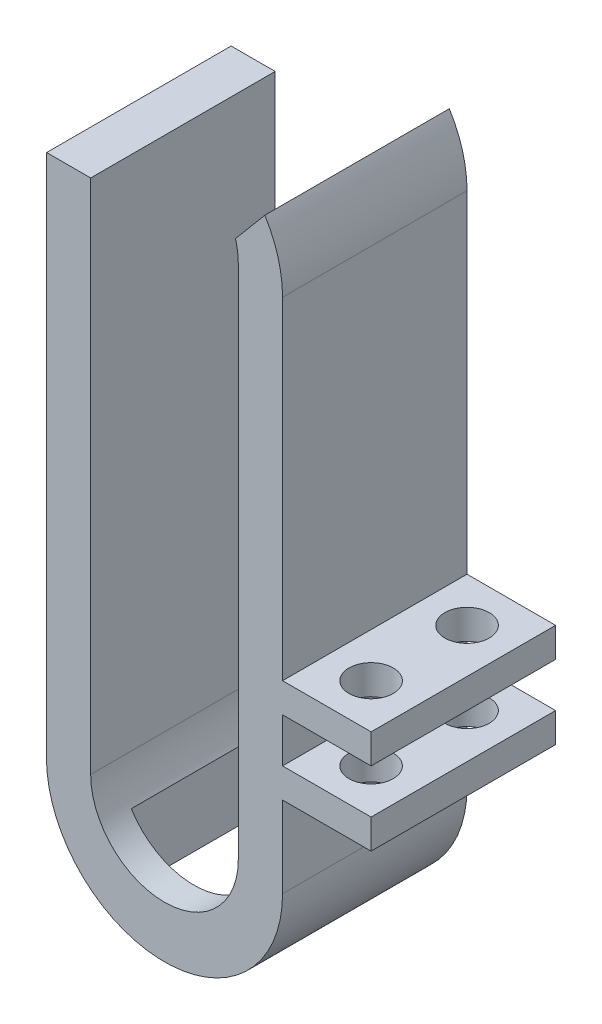
from build123d import *

# Parameters (mm, degrees)
BOSS_EXTRUDE1_DEPTH     = 12.5
SKETCH2_W               = 12.5
SKETCH2_H               = 2
BOSS_EXTRUDE2_DEPTH     = 6
SKETCH3_R               = 1.5
CUT_EXTRUDE1_DEPTH      = 32.713927878
CUT_EXTRUDE1_DEPTH_BACK = 16.499999831
SKETCH5_W               = 8.5
SKETCH5_H               = 8.5
CUT_EXTRUDE2_DEPTH      = 26.999999831


with BuildPart() as part:
    # Sketch1 → Boss-Extrude1 (new body)
    with BuildSketch(Plane.XY):
        with BuildLine():
            ThreePointArc((8, 17), (7.694207367, 19.190701486), (6.80020675, 21.213927878))
            Line((6.80020675, 21.213927878), (4.814885895, 18.847914617))
            ThreePointArc((4.814885895, 18.847914617), (4.953505298, 18.180283222), (5, 17.5))
            Line((5, 17.5), (5, -17.5))
            ThreePointArc((5, -17.5), (0, -22.5), (-5, -17.5))
            Line((-5, -17.5), (-5, 17.5))
            Line((-5, 17.5), (-7.984359711, 17.5))
            ThreePointArc((-7.984359711, 17.5), (-7.996088972, 17.250122279), (-8, 17))
            Line((-8, 17), (-8, -17.999999662))
            ThreePointArc((-8, -17.999999662), (-1.69e-07, -25.999999831), (8, -18))
            Line((8, -18), (8, 17))
        make_face()
    extrude(amount=BOSS_EXTRUDE1_DEPTH)

    # Sketch2 → Boss-Extrude2 (add)
    with BuildSketch(Plane(origin=(8, 0, 0), x_dir=(0, 0, -1), z_dir=(1, 0, 0))):
        with Locations((-6.25, -11.5)):
            Rectangle(SKETCH2_W, SKETCH2_H)
        with Locations((-6.25, -6.5)):
            Rectangle(SKETCH2_W, SKETCH2_H)
    extrude(amount=BOSS_EXTRUDE2_DEPTH)

    # Sketch3 → Cut-Extrude1 (cut, two sides)
    with BuildSketch(Plane(origin=(0, -10.5, 0), x_dir=(1, 0, 0), z_dir=(0, 1, 0))) as cut_extrude1_sk:
        with Locations((11, -3)):
            Circle(SKETCH3_R)
        with Locations((11, -9.5)):
            Circle(SKETCH3_R)
    extrude(amount=CUT_EXTRUDE1_DEPTH, mode=Mode.SUBTRACT)
    extrude(cut_extrude1_sk.sketch, amount=-CUT_EXTRUDE1_DEPTH_BACK, mode=Mode.SUBTRACT)

    # Sketch5 → Cut-Extrude2 (cut, through all)
    with BuildSketch(Plane(origin=(0, 0, 0), x_dir=(1, 0, 0), z_dir=(0, 1, 0))):
        with Locations((0, -6.25)):
            Rectangle(SKETCH5_W, SKETCH5_H)
    extrude(amount=-CUT_EXTRUDE2_DEPTH, mode=Mode.SUBTRACT)


solid = part.part
